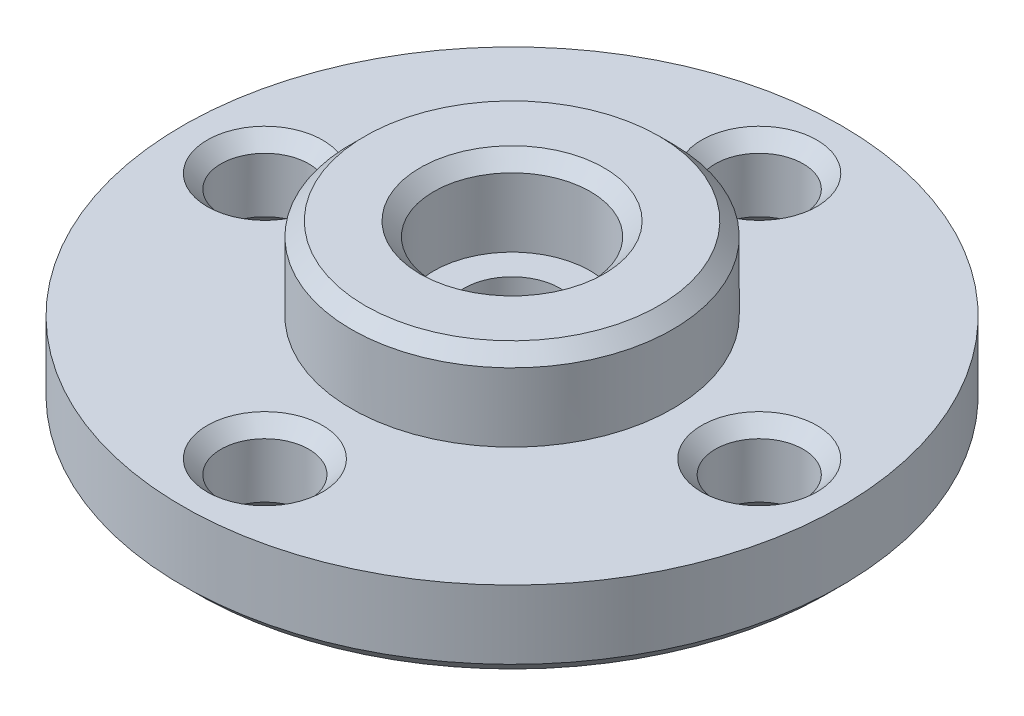
from build123d import *

# Parameters (mm, degrees)
SKETCH2_R          = 1.6
CUT_EXTRUDE1_DEPTH = 4
CIRPATTERN1_COUNT  = 4
CHAMFER1_SIZE      = 0.5


with BuildPart() as part:
    # Sketch1 → Revolve1 (revolve)
    with BuildSketch(Plane.XY):
        Polygon((1.75, 0), (1.75, 3), (2.85, 3), (2.85, 6), (5.85, 6), (5.85, 3), (12, 3), (12, 0), align=None)
    revolve(axis=Axis((0, -26.625979541, 0), (0, 1, 0)))

    # Sketch2 → Cut-Extrude1 (cut, through all)
    with BuildSketch(Plane(origin=(0, 3, 0), x_dir=(1, 0, 0), z_dir=(0, 1, 0))):
        with Locations((9, 0)):
            Circle(SKETCH2_R)
    cut_extrude1 = extrude(amount=-CUT_EXTRUDE1_DEPTH, mode=Mode.SUBTRACT)

    # CirPattern1: Cut-Extrude1 ×4 about axis
    cirpattern1_axis = Axis((0, 0, 0), (0, 1, 0))
    for i in range(1, CIRPATTERN1_COUNT):
        add(cut_extrude1.rotate(cirpattern1_axis, i * 360 / CIRPATTERN1_COUNT), mode=Mode.SUBTRACT)

    # Chamfer1
    chamfer1_edges = [part.edges().sort_by_distance(p)[0] for p in [
        (7.4, 0, 0),
        (7.4, 3, 0),
        (0, 0, 7.4),
        (0, 3, 7.4),
        (-7.4, 0, 0),
        (-7.4, 3, 0),
        (0, 0, -7.4),
        (0, 3, -7.4),
        (-12, 0, 0),
        (-5.85, 6, 0),
        (-2.85, 6, 0),
        (-1.75, 0, 0),
    ]]
    chamfer(chamfer1_edges, length=CHAMFER1_SIZE)


solid = part.part
